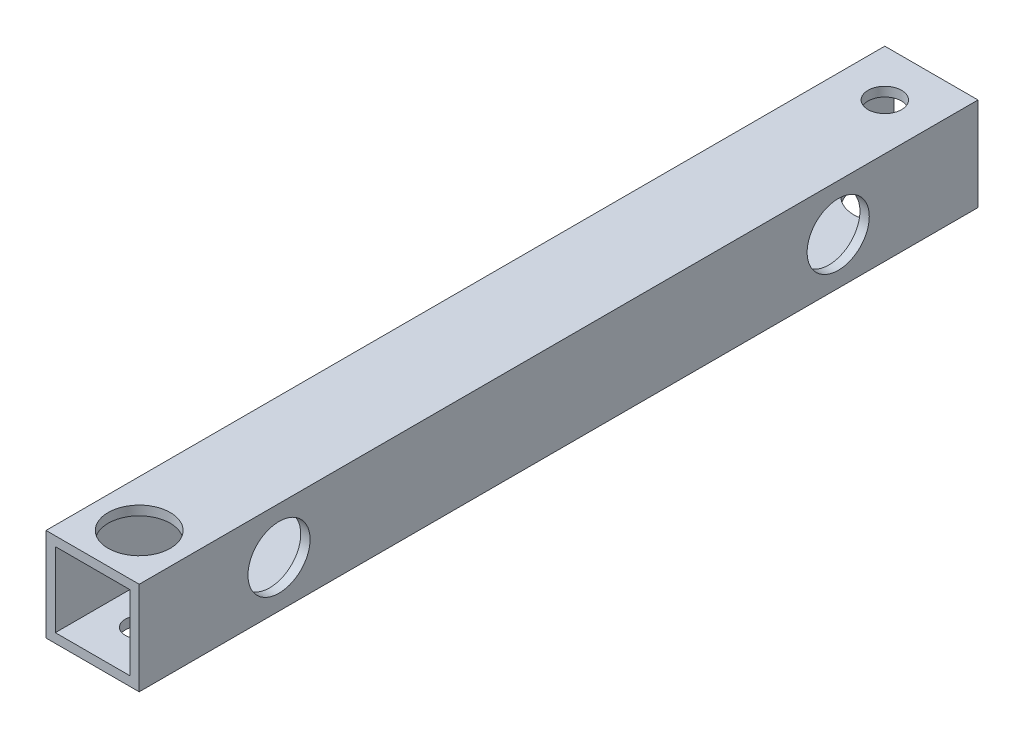
from build123d import *

# Parameters (mm, degrees)
SKETCH_1_W          = 15
SKETCH_1_H          = 15
SKETCH_1_W_2        = 12
SKETCH_1_H_2        = 12
EXTRUDE_1_DEPTH     = 135
SKETCH_2_R          = 2.7
CUT_EXTRUDE_1_DEPTH = 25
SKETCH_3_R          = 2.7
SKETCH_3_R_2        = 2.25
CUT_EXTRUDE_2_DEPTH = 25
SKETCH_4_R          = 5
CUT_EXTRUDE_3_DEPTH = 10
SKETCH_5_R          = 5
CUT_EXTRUDE_4_DEPTH = 10
SKETCH_6_R          = 5
CUT_EXTRUDE_5_DEPTH = 10


with BuildPart() as part:
    # ｽｹｯﾁ1 → ﾎﾞｽ - 押し出し1 (new body)
    with BuildSketch(Plane.XY):
        Rectangle(SKETCH_1_W, SKETCH_1_H)
        Rectangle(SKETCH_1_W_2, SKETCH_1_H_2, mode=Mode.SUBTRACT)
    extrude(amount=EXTRUDE_1_DEPTH)

    # ｽｹｯﾁ2 → ｶｯﾄ - 押し出し1 (cut)
    with BuildSketch(Plane(origin=(7.5, 0, 0), x_dir=(0, 0, -1), z_dir=(1, 0, 0))):
        with Locations((-112.5, 0)):
            Circle(SKETCH_2_R)
        with Locations((-22.5, 0)):
            Circle(SKETCH_2_R)
    extrude(amount=-CUT_EXTRUDE_1_DEPTH, mode=Mode.SUBTRACT)

    # ｽｹｯﾁ3 → ｶｯﾄ - 押し出し2 (cut)
    with BuildSketch(Plane(origin=(0, 7.5, 0), x_dir=(1, 0, 0), z_dir=(0, 1, 0))):
        with Locations((0, -7.5)):
            Circle(SKETCH_3_R)
        with Locations((0, -127.5)):
            Circle(SKETCH_3_R_2)
    extrude(amount=-CUT_EXTRUDE_2_DEPTH, mode=Mode.SUBTRACT)

    # ｽｹｯﾁ4 → ｶｯﾄ - 押し出し3 (cut)
    with BuildSketch(Plane(origin=(0, 7.5, 0), x_dir=(1, 0, 0), z_dir=(0, 1, 0))):
        with Locations((0, -127.5)):
            Circle(SKETCH_4_R)
    extrude(amount=-CUT_EXTRUDE_3_DEPTH, mode=Mode.SUBTRACT)

    # ｽｹｯﾁ5 → ｶｯﾄ - 押し出し4 (cut)
    with BuildSketch(Plane(origin=(7.5, 0, 0), x_dir=(0, 0, -1), z_dir=(1, 0, 0))):
        with Locations((-22.5, 0)):
            Circle(SKETCH_5_R)
        with Locations((-112.5, 0)):
            Circle(SKETCH_5_R)
    extrude(amount=-CUT_EXTRUDE_4_DEPTH, mode=Mode.SUBTRACT)

    # ｽｹｯﾁ6 → ｶｯﾄ - 押し出し5 (cut)
    with BuildSketch(Plane(origin=(0, -7.5, 0), x_dir=(-1, 0, 0), z_dir=(0, -1, 0))):
        with Locations((0, -7.5)):
            Circle(SKETCH_6_R)
    extrude(amount=-CUT_EXTRUDE_5_DEPTH, mode=Mode.SUBTRACT)


solid = part.part
